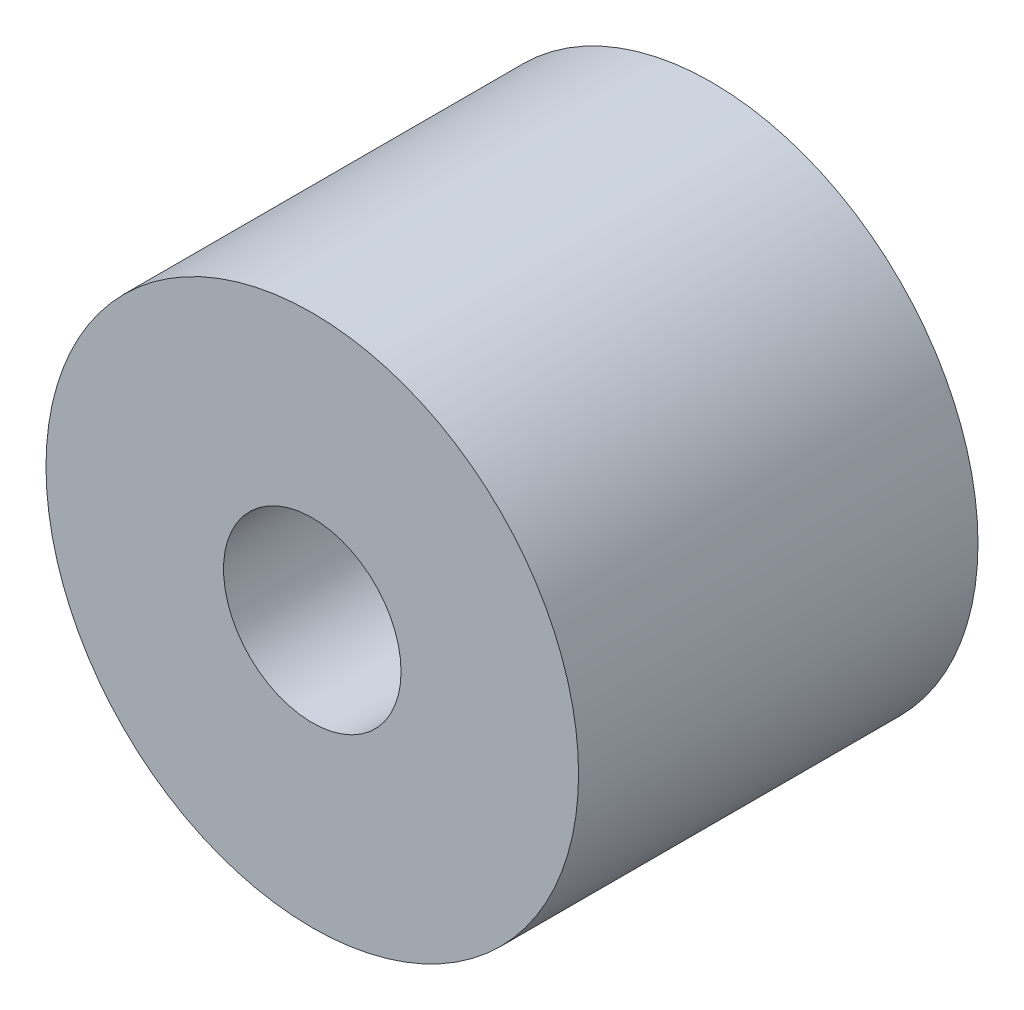
from build123d import *

# Parameters (mm, degrees)
SKETCH1_R           = 12
SKETCH1_R_2         = 4
BOSS_EXTRUDE1_DEPTH = 18


with BuildPart() as part:
    # Sketch1 → Boss-Extrude1 (new body)
    with BuildSketch(Plane.XY):
        Circle(SKETCH1_R)
        Circle(SKETCH1_R_2, mode=Mode.SUBTRACT)
    extrude(amount=BOSS_EXTRUDE1_DEPTH)


solid = part.part
